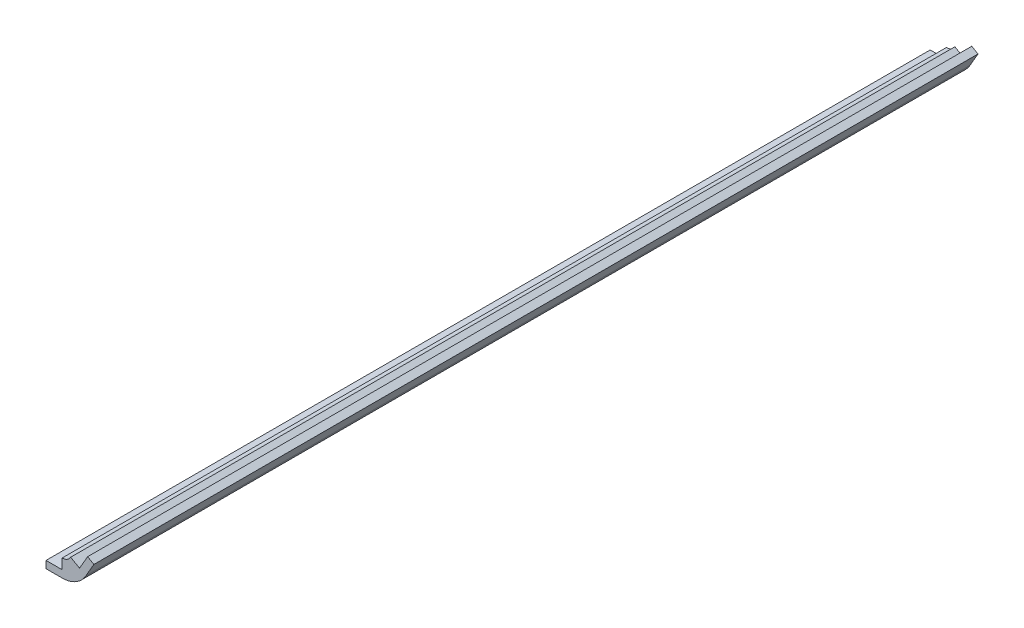
from build123d import *

# Parameters (mm, degrees)
SKETCH7_W           = 4.7625
SKETCH7_H           = 2.12122512
BOSS_EXTRUDE2_DEPTH = 130.175
BOSS_EXTRUDE3_DEPTH = 130.175
BOSS_EXTRUDE4_DEPTH = 130.175


with BuildPart() as part:
    # Sketch7 → Boss-Extrude2 (new, symmetric)
    with BuildSketch(Plane.XY):
        with Locations((-4.92125, -2.560612608)):
            Rectangle(SKETCH7_W, SKETCH7_H)
    extrude(amount=BOSS_EXTRUDE2_DEPTH, both=True)



with BuildPart() as body_2:
    # Sketch8 → Boss-Extrude3 (new, symmetric)
    with BuildSketch(Plane.XY):
        Polygon((2.569038147, 1.449704502), (4.950288147, 5.574150487), (6.787322988, 4.513537927), (4.406072988, 0.389091942), align=None)
    extrude(amount=BOSS_EXTRUDE3_DEPTH, both=True)


with BuildPart() as part_1:
    add(part.part)

    add(body_2.part)  # Boss-Extrude4 merges body 2
    # Sketch11 → Boss-Extrude4 (add, symmetric)
    with BuildSketch(Plane.XY):
        with BuildLine():
            Line((-2.54, -1.500000048), (-7.3025, -1.500000048))
            Line((-7.3025, -1.500000048), (-7.3025, -3.621225168))
            Line((-7.3025, -3.621225168), (-2.54, -3.621225168))
            ThreePointArc((-2.54, -3.621225168), (1.47031711, -2.546663937), (4.406072988, 0.389091942))
            Line((4.406072988, 0.389091942), (6.787322988, 4.513537927))
            Line((6.787322988, 4.513537927), (4.950288147, 5.574150487))
            Line((4.950288147, 5.574150487), (2.569038147, 1.449704502))
            Line((2.569038147, 1.449704502), (-0.029038147, 2.94970455))
            ThreePointArc((-0.029038147, 2.94970455), (-1.090295498, 1.888447198), (-2.54, 1.500000048))
            Line((-2.54, 1.500000048), (-2.54, -1.500000048))
        make_face()
    extrude(amount=BOSS_EXTRUDE4_DEPTH, both=True)


solid = part_1.part
